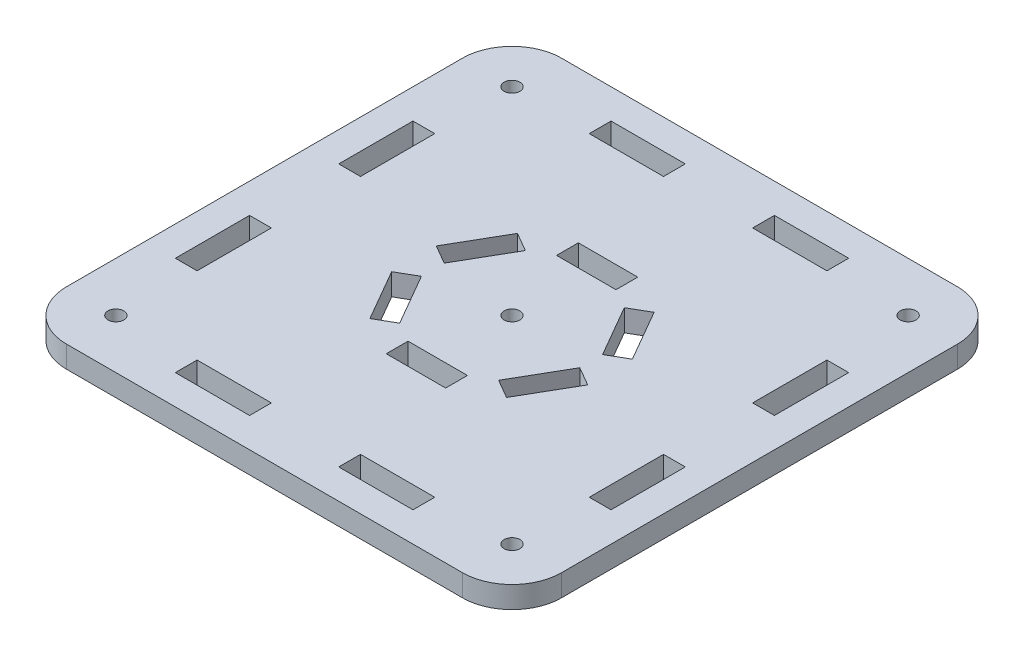
from build123d import *

# Parameters (mm, degrees)
SKETCH_1_W          = 100
SKETCH_1_H          = 100
SKETCH_1_R          = 1.6
EXTRUDE_1_DEPTH     = 4.4
FILLET_1_R          = 10
CUT_EXTRUDE_1_REACH = 6.4
SKETCH_2_R          = 1.6
SKETCH_2_W          = 15
SKETCH_2_H          = 4.4
SKETCH_2_W_2        = 4.4
SKETCH_2_H_2        = 15
SKETCH_3_W          = 12
SKETCH_3_H          = 4.4
CUT_EXTRUDE_2_DEPTH = 5.4


with BuildPart() as part:
    # 草图1 → 凸台-拉伸1 (new body)
    with BuildSketch(Plane(origin=(0, 0, 0), x_dir=(1, 0, 0), z_dir=(0, 1, 0))):
        Rectangle(SKETCH_1_W, SKETCH_1_H)
        Circle(SKETCH_1_R, mode=Mode.SUBTRACT)
    extrude(amount=EXTRUDE_1_DEPTH)

    # 圆角1
    fillet_1_edges = [part.edges().sort_by_distance(p)[0] for p in [
        (50, 2.2, 50),
        (-50, 2.2, 50),
        (-50, 2.2, -50),
        (50, 2.2, -50),
    ]]
    fillet(fillet_1_edges, radius=FILLET_1_R)

    # 草图2 → 切除-拉伸1 (cut, up to next)
    with BuildSketch(Plane(origin=(0, 4.4, 0), x_dir=(1, 0, 0), z_dir=(0, 1, 0)), mode=Mode.PRIVATE) as cut_extrude_1_sk1:
        with Locations((40, 40)):
            Circle(SKETCH_2_R)
    cut_extrude_1_tool1 = extrude(cut_extrude_1_sk1.sketch, amount=-CUT_EXTRUDE_1_REACH, mode=Mode.PRIVATE) & part.part
    add(cut_extrude_1_tool1.solids().sort_by_distance((40, 4.4, -40))[0], mode=Mode.SUBTRACT)
    # 草图2 → 切除-拉伸1 (cut, up to next)
    with BuildSketch(Plane(origin=(0, 4.4, 0), x_dir=(1, 0, 0), z_dir=(0, 1, 0)), mode=Mode.PRIVATE) as cut_extrude_1_sk2:
        with Locations((40, -40)):
            Circle(SKETCH_2_R)
    cut_extrude_1_tool2 = extrude(cut_extrude_1_sk2.sketch, amount=-CUT_EXTRUDE_1_REACH, mode=Mode.PRIVATE) & part.part
    add(cut_extrude_1_tool2.solids().sort_by_distance((40, 4.4, 40))[0], mode=Mode.SUBTRACT)
    # 草图2 → 切除-拉伸1 (cut, up to next)
    with BuildSketch(Plane(origin=(0, 4.4, 0), x_dir=(1, 0, 0), z_dir=(0, 1, 0)), mode=Mode.PRIVATE) as cut_extrude_1_sk3:
        with Locations((-40, -40)):
            Circle(SKETCH_2_R)
    cut_extrude_1_tool3 = extrude(cut_extrude_1_sk3.sketch, amount=-CUT_EXTRUDE_1_REACH, mode=Mode.PRIVATE) & part.part
    add(cut_extrude_1_tool3.solids().sort_by_distance((-40, 4.4, 40))[0], mode=Mode.SUBTRACT)
    # 草图2 → 切除-拉伸1 (cut, up to next)
    with BuildSketch(Plane(origin=(0, 4.4, 0), x_dir=(1, 0, 0), z_dir=(0, 1, 0)), mode=Mode.PRIVATE) as cut_extrude_1_sk4:
        with Locations((-40, 40)):
            Circle(SKETCH_2_R)
    cut_extrude_1_tool4 = extrude(cut_extrude_1_sk4.sketch, amount=-CUT_EXTRUDE_1_REACH, mode=Mode.PRIVATE) & part.part
    add(cut_extrude_1_tool4.solids().sort_by_distance((-40, 4.4, -40))[0], mode=Mode.SUBTRACT)
    # 草图2 → 切除-拉伸1 (cut, up to next)
    with BuildSketch(Plane(origin=(0, 4.4, 0), x_dir=(1, 0, 0), z_dir=(0, 1, 0)), mode=Mode.PRIVATE) as cut_extrude_1_sk5:
        with Locations((-16.5, 41.8)):
            Rectangle(SKETCH_2_W, SKETCH_2_H)
    cut_extrude_1_tool5 = extrude(cut_extrude_1_sk5.sketch, amount=-CUT_EXTRUDE_1_REACH, mode=Mode.PRIVATE) & part.part
    add(cut_extrude_1_tool5.solids().sort_by_distance((-16.5, 4.4, -41.8))[0], mode=Mode.SUBTRACT)
    # 草图2 → 切除-拉伸1 (cut, up to next)
    with BuildSketch(Plane(origin=(0, 4.4, 0), x_dir=(1, 0, 0), z_dir=(0, 1, 0)), mode=Mode.PRIVATE) as cut_extrude_1_sk6:
        with Locations((16.5, 41.8)):
            Rectangle(SKETCH_2_W, SKETCH_2_H)
    cut_extrude_1_tool6 = extrude(cut_extrude_1_sk6.sketch, amount=-CUT_EXTRUDE_1_REACH, mode=Mode.PRIVATE) & part.part
    add(cut_extrude_1_tool6.solids().sort_by_distance((16.5, 4.4, -41.8))[0], mode=Mode.SUBTRACT)
    # 草图2 → 切除-拉伸1 (cut, up to next)
    with BuildSketch(Plane(origin=(0, 4.4, 0), x_dir=(1, 0, 0), z_dir=(0, 1, 0)), mode=Mode.PRIVATE) as cut_extrude_1_sk7:
        with Locations((41.8, -16.5)):
            Rectangle(SKETCH_2_W_2, SKETCH_2_H_2)
    cut_extrude_1_tool7 = extrude(cut_extrude_1_sk7.sketch, amount=-CUT_EXTRUDE_1_REACH, mode=Mode.PRIVATE) & part.part
    add(cut_extrude_1_tool7.solids().sort_by_distance((41.8, 4.4, 16.5))[0], mode=Mode.SUBTRACT)
    # 草图2 → 切除-拉伸1 (cut, up to next)
    with BuildSketch(Plane(origin=(0, 4.4, 0), x_dir=(1, 0, 0), z_dir=(0, 1, 0)), mode=Mode.PRIVATE) as cut_extrude_1_sk8:
        with Locations((41.8, 16.5)):
            Rectangle(SKETCH_2_W_2, SKETCH_2_H_2)
    cut_extrude_1_tool8 = extrude(cut_extrude_1_sk8.sketch, amount=-CUT_EXTRUDE_1_REACH, mode=Mode.PRIVATE) & part.part
    add(cut_extrude_1_tool8.solids().sort_by_distance((41.8, 4.4, -16.5))[0], mode=Mode.SUBTRACT)
    # 草图2 → 切除-拉伸1 (cut, up to next)
    with BuildSketch(Plane(origin=(0, 4.4, 0), x_dir=(1, 0, 0), z_dir=(0, 1, 0)), mode=Mode.PRIVATE) as cut_extrude_1_sk9:
        with Locations((-16.5, -41.8)):
            Rectangle(SKETCH_2_W, SKETCH_2_H)
    cut_extrude_1_tool9 = extrude(cut_extrude_1_sk9.sketch, amount=-CUT_EXTRUDE_1_REACH, mode=Mode.PRIVATE) & part.part
    add(cut_extrude_1_tool9.solids().sort_by_distance((-16.5, 4.4, 41.8))[0], mode=Mode.SUBTRACT)
    # 草图2 → 切除-拉伸1 (cut, up to next)
    with BuildSketch(Plane(origin=(0, 4.4, 0), x_dir=(1, 0, 0), z_dir=(0, 1, 0)), mode=Mode.PRIVATE) as cut_extrude_1_sk10:
        with Locations((16.5, -41.8)):
            Rectangle(SKETCH_2_W, SKETCH_2_H)
    cut_extrude_1_tool10 = extrude(cut_extrude_1_sk10.sketch, amount=-CUT_EXTRUDE_1_REACH, mode=Mode.PRIVATE) & part.part
    add(cut_extrude_1_tool10.solids().sort_by_distance((16.5, 4.4, 41.8))[0], mode=Mode.SUBTRACT)
    # 草图2 → 切除-拉伸1 (cut, up to next)
    with BuildSketch(Plane(origin=(0, 4.4, 0), x_dir=(1, 0, 0), z_dir=(0, 1, 0)), mode=Mode.PRIVATE) as cut_extrude_1_sk11:
        with Locations((-41.8, 16.5)):
            Rectangle(SKETCH_2_W_2, SKETCH_2_H_2)
    cut_extrude_1_tool11 = extrude(cut_extrude_1_sk11.sketch, amount=-CUT_EXTRUDE_1_REACH, mode=Mode.PRIVATE) & part.part
    add(cut_extrude_1_tool11.solids().sort_by_distance((-41.8, 4.4, -16.5))[0], mode=Mode.SUBTRACT)
    # 草图2 → 切除-拉伸1 (cut, up to next)
    with BuildSketch(Plane(origin=(0, 4.4, 0), x_dir=(1, 0, 0), z_dir=(0, 1, 0)), mode=Mode.PRIVATE) as cut_extrude_1_sk12:
        with Locations((-41.8, -16.5)):
            Rectangle(SKETCH_2_W_2, SKETCH_2_H_2)
    cut_extrude_1_tool12 = extrude(cut_extrude_1_sk12.sketch, amount=-CUT_EXTRUDE_1_REACH, mode=Mode.PRIVATE) & part.part
    add(cut_extrude_1_tool12.solids().sort_by_distance((-41.8, 4.4, 16.5))[0], mode=Mode.SUBTRACT)

    # 草图3 → 切除-拉伸2 (cut, through all)
    with BuildSketch(Plane(origin=(0, 4.4, 0), x_dir=(1, 0, 0), z_dir=(0, 1, 0))):
        with Locations((0, 17.2)):
            Rectangle(SKETCH_3_W, SKETCH_3_H)
        Polygon((13.800892833, 14.896152423), (9.990381057, 12.696152423), (15.990381057, 2.303847577), (19.800892833, 4.503847577), align=None)
        Polygon((19.800892833, -4.503847577), (15.990381057, -2.303847577), (9.990381057, -12.696152423), (13.800892833, -14.896152423), align=None)
        with Locations((0, -17.2)):
            Rectangle(SKETCH_3_W, SKETCH_3_H)
        Polygon((-13.800892833, -14.896152423), (-9.990381057, -12.696152423), (-15.990381057, -2.303847577), (-19.800892833, -4.503847577), align=None)
        Polygon((-19.800892833, 4.503847577), (-15.990381057, 2.303847577), (-9.990381057, 12.696152423), (-13.800892833, 14.896152423), align=None)
    extrude(amount=-CUT_EXTRUDE_2_DEPTH, mode=Mode.SUBTRACT)


solid = part.part
